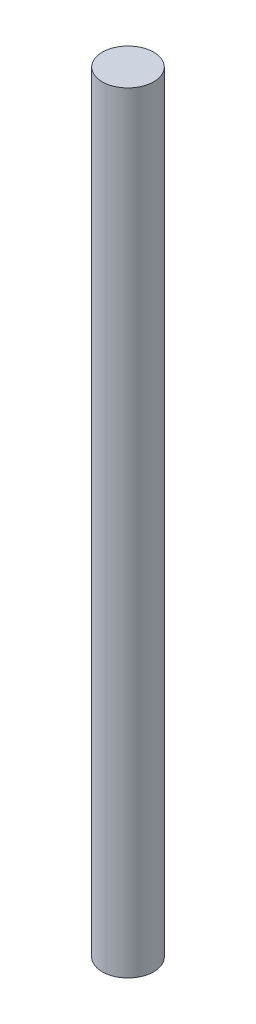
from build123d import *

# Parameters (mm, degrees)
SKETCH1_R           = 7.5
BOSS_EXTRUDE1_DEPTH = 225


with BuildPart() as part:
    # Sketch1 → Boss-Extrude1 (new body)
    with BuildSketch(Plane(origin=(0, 0, 0), x_dir=(1, 0, 0), z_dir=(0, 1, 0))):
        Circle(SKETCH1_R)
    extrude(amount=BOSS_EXTRUDE1_DEPTH)


solid = part.part
